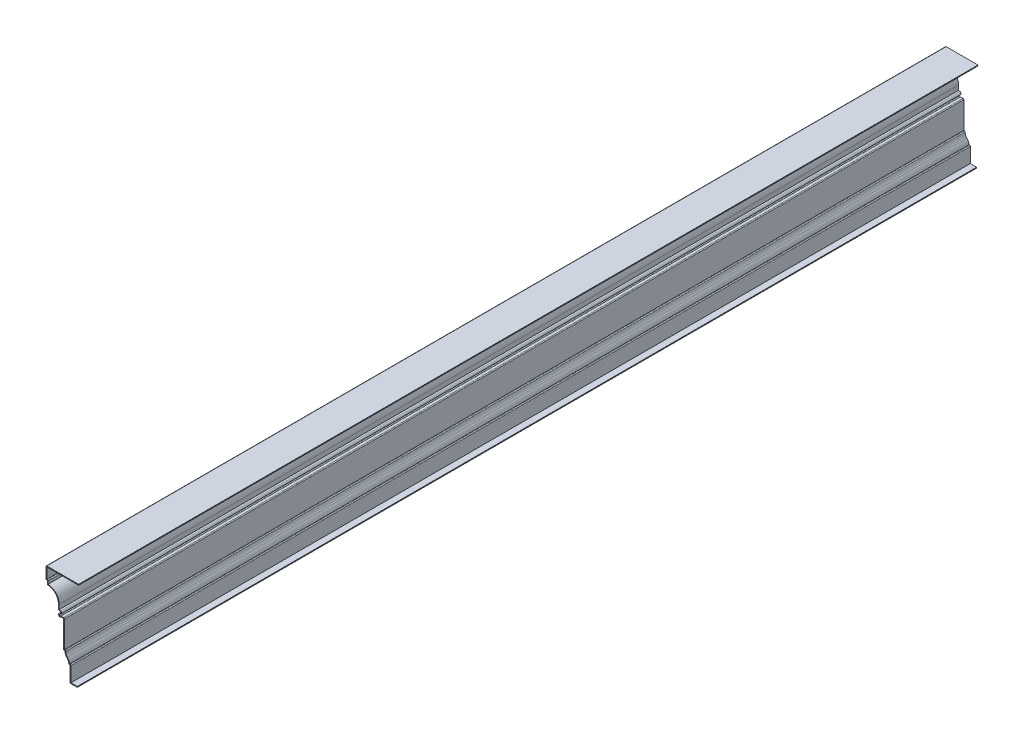
from build123d import *

# Parameters (mm, degrees)
EXTRUDE_THIN1_DEPTH = 1095.375
FILLET1_R           = 1.016


with BuildPart() as part:
    # Sketch1 → Extrude-Thin1 (new body)
    with BuildSketch(Plane.XY):
        with BuildLine():
            Line((0, 0), (-8.73125, 0))
            Line((-8.73125, 0), (-8.73125, 19.05))
            Line((-8.73125, 19.05), (-10.31875, 19.05))
            ThreePointArc((-10.31875, 19.05), (-10.936141439, 22.255855924), (-12.7, 25.003125))
            ThreePointArc((-12.7, 25.003125), (-14.463858561, 27.750394076), (-15.08125, 30.95625))
            Line((-15.08125, 30.95625), (-16.66875, 30.95625))
            Line((-16.66875, 30.95625), (-16.66875, 64.29375))
            Line((-16.66875, 64.29375), (-19.690990213, 64.29375))
            ThreePointArc((-19.690990213, 64.29375), (-22.556015121, 64.295224921), (-22.148203112, 67.131077398))
            Line((-22.148203112, 67.131077398), (-20.250068746, 68.351516354))
            ThreePointArc((-20.250068746, 68.351516354), (-19.937393927, 69.05810986), (-20.463483992, 69.624033147))
            Line((-20.463483992, 69.624033147), (-23.01875, 70.246875))
            Line((-23.01875, 70.246875), (-23.01875, 76.596875))
            ThreePointArc((-23.01875, 76.596875), (-26.970977871, 86.138397129), (-36.5125, 90.090625))
            Line((-36.5125, 90.090625), (-36.5125, 94.45625))
            Line((-36.5125, 94.45625), (-38.1, 94.45625))
            Line((-38.1, 94.45625), (-38.1, 109.5375))
            Line((-38.1, 109.5375), (1.5875, 109.5375))
            Line((1.5875, 109.5375), (1.5875, 108.5215))
            Line((1.5875, 108.5215), (-37.084, 108.5215))
            Line((-37.084, 108.5215), (-37.084, 95.47225))
            Line((-37.084, 95.47225), (-35.4965, 95.47225))
            Line((-35.4965, 95.47225), (-35.4965, 91.071010175))
            ThreePointArc((-35.4965, 91.071010175), (-25.899424313, 86.491088942), (-22.00275, 76.596875))
            Line((-22.00275, 76.596875), (-22.00275, 71.044973159))
            Line((-22.00275, 71.044973159), (-20.222880084, 70.611132818))
            ThreePointArc((-20.222880084, 70.611132818), (-18.935387932, 69.226157431), (-19.700592224, 67.496921976))
            Line((-19.700592224, 67.496921976), (-21.59872659, 66.27648302))
            ThreePointArc((-21.59872659, 66.27648302), (-21.64120221, 64.825375438), (-20.272663327, 65.30975))
            Line((-20.272663327, 65.30975), (-15.65275, 65.30975))
            Line((-15.65275, 65.30975), (-15.65275, 31.97225))
            Line((-15.65275, 31.97225), (-13.99717715, 31.97225))
            ThreePointArc((-13.99717715, 31.97225), (-13.693796997, 28.60677814), (-11.964275862, 25.703814655))
            ThreePointArc((-11.964275862, 25.703814655), (-10.194199045, 23.100527755), (-9.356394818, 20.066))
            Line((-9.356394818, 20.066), (-7.71525, 20.066))
            Line((-7.71525, 20.066), (-7.71525, 1.016))
            Line((-7.71525, 1.016), (0, 1.016))
            Line((0, 1.016), (0, 0))
        make_face()
    extrude(amount=-EXTRUDE_THIN1_DEPTH)

    # Fillet1
    fillet1_edges = [part.edges().sort_by_distance(p)[0] for p in [
        (-35.4965, 95.47225, -547.6875),
        (-20.272663327, 65.30975, -547.6875),
        (-15.65275, 65.30975, -547.6875),
        (-13.99717715, 31.97225, -547.6875),
        (-7.71525, 20.066, -547.6875),
        (-8.73125, 0, -547.6875),
        (-10.31875, 19.05, -547.6875),
        (-16.66875, 30.95625, -547.6875),
        (-23.01875, 70.246875, -547.6875),
        (-36.5125, 90.090625, -547.6875),
        (-38.1, 94.45625, -547.6875),
        (-38.1, 109.5375, -547.6875),
    ]]
    fillet(fillet1_edges, radius=FILLET1_R)


solid = part.part
